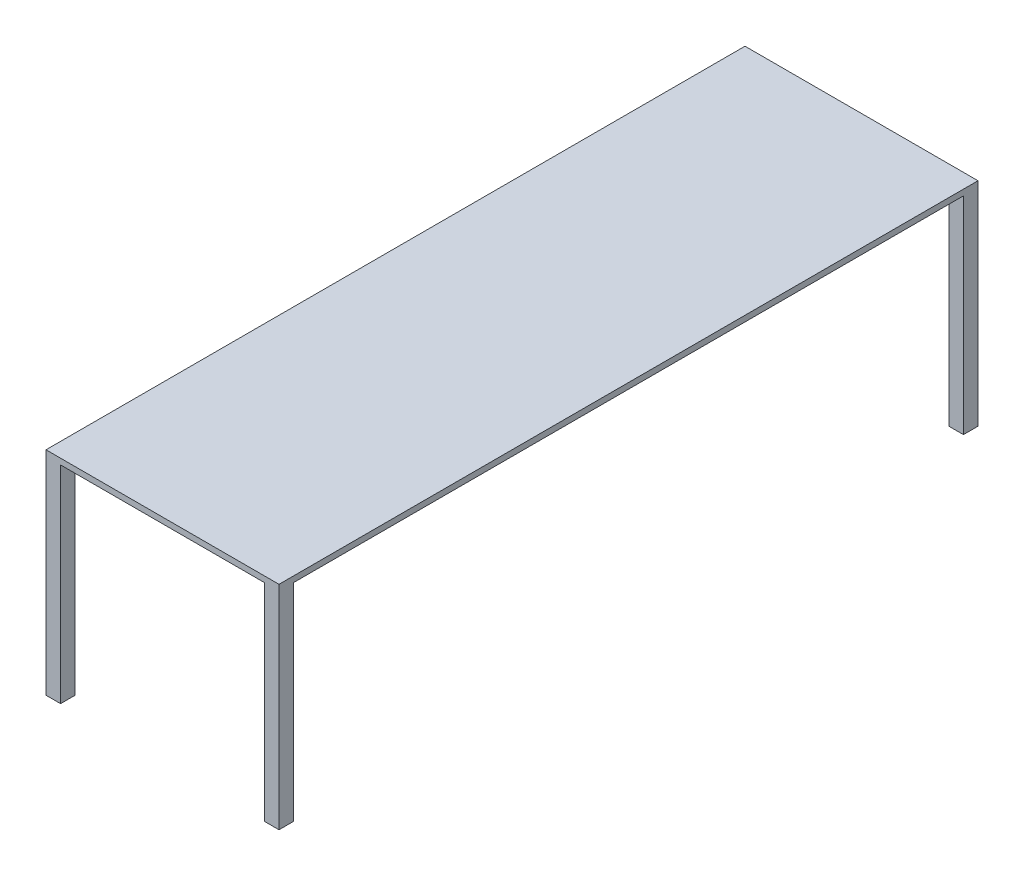
from build123d import *

# Parameters (mm, degrees)
SKETCH_1_W               = 800
SKETCH_1_H               = 2400
EXTRUDE_1_DEPTH          = 20
SKETCH_2_W               = 50
SKETCH_2_H               = 50
EXTRUDE_2_DEPTH          = 710
MIRROR_2_COPY_1_SKETCH_W = 50
MIRROR_2_COPY_1_SKETCH_H = 50
MIRROR_2_COPY_1_DEPTH    = 710


with BuildPart() as part:
    # 草图1 → 凸台-拉伸1 (new body)
    with BuildSketch(Plane(origin=(0, 0, 0), x_dir=(1, 0, 0), z_dir=(0, 1, 0))):
        Rectangle(SKETCH_1_W, SKETCH_1_H)
    extrude(amount=EXTRUDE_1_DEPTH)

    # 草图2 → 凸台-拉伸2 (add)
    with BuildSketch(Plane(origin=(0, 0, 0), x_dir=(-1, 0, 0), z_dir=(0, -1, 0))):
        with Locations((-375, -1175)):
            Rectangle(SKETCH_2_W, SKETCH_2_H)
    extrude_2 = extrude(amount=EXTRUDE_2_DEPTH)

    # 镜向1: 凸台-拉伸2 across plane
    add(extrude_2.mirror(Plane.XY))

    # 镜向2: 凸台-拉伸2 across plane
    add(extrude_2.mirror(Plane(origin=(0, 0, 0), x_dir=(0, 0, 1), z_dir=(1, 0, 0))))

    # 镜向2 copy 1 sketch → 镜向2 copy 1 (add)
    with BuildSketch(Plane.XZ):
        with Locations((-375, -1175)):
            Rectangle(MIRROR_2_COPY_1_SKETCH_W, MIRROR_2_COPY_1_SKETCH_H)
    extrude(amount=MIRROR_2_COPY_1_DEPTH)


solid = part.part
